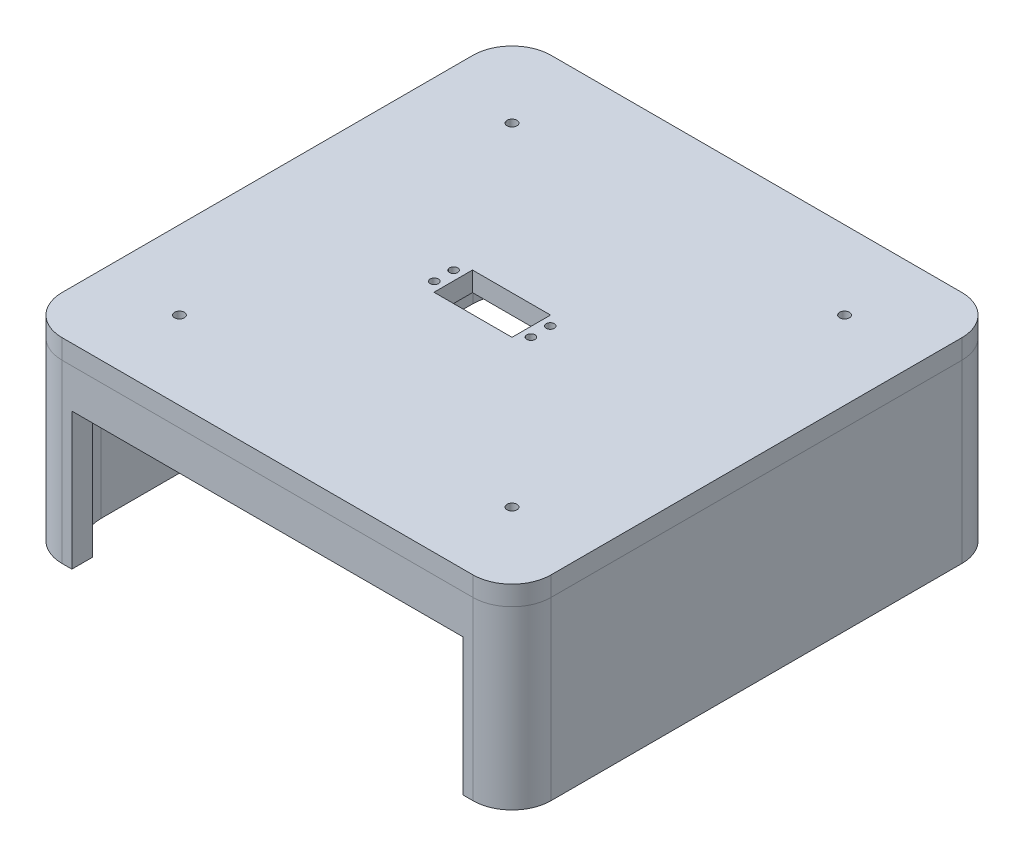
from build123d import *

# Parameters (mm, degrees)
SKETCH1_W            = 250
SKETCH1_H            = 250
SKETCH1_W_2          = 230
SKETCH1_H_2          = 230
BOSS_EXTRUDE1_DEPTH  = 90
SKETCH2_W            = 200
SKETCH2_H            = 70
CUT_EXTRUDE1_DEPTH   = 50
FILLET1_R            = 20
BOSS_EXTRUDE2_DEPTH  = 10
SKETCH4_R            = 2.5
CUT_EXTRUDE2_DEPTH   = 10
LPATTERN1_COUNT      = 2
LPATTERN1_PITCH      = 170
LPATTERN1_COUNT_DIR2 = 2
LPATTERN1_PITCH_DIR2 = 170
SKETCH6_R            = 2.1
SKETCH6_W            = 39.9
SKETCH6_H            = 19.7
CUT_EXTRUDE3_DEPTH   = 10


with BuildPart() as part:
    # Sketch1 → Boss-Extrude1 (new body)
    with BuildSketch(Plane(origin=(0, 0, 0), x_dir=(1, 0, 0), z_dir=(0, 1, 0))):
        Rectangle(SKETCH1_W, SKETCH1_H)
        Rectangle(SKETCH1_W_2, SKETCH1_H_2, mode=Mode.SUBTRACT)
    extrude(amount=BOSS_EXTRUDE1_DEPTH)

    # Sketch2 → Cut-Extrude1 (cut)
    with BuildSketch(Plane.XY.offset(125)):
        with Locations((0, 35)):
            Rectangle(SKETCH2_W, SKETCH2_H)
    extrude(amount=-CUT_EXTRUDE1_DEPTH, mode=Mode.SUBTRACT)

    # Fillet1
    fillet1_edges = [part.edges().sort_by_distance(p)[0] for p in [
        (-115, 45, 115),
        (115, 45, 115),
        (115, 45, -115),
        (-115, 45, -115),
        (-125, 45, 125),
        (125, 45, 125),
        (125, 45, -125),
        (-125, 45, -125),
    ]]
    fillet(fillet1_edges, radius=FILLET1_R)


with BuildPart() as body_2:
    # Sketch3 → Boss-Extrude2 (new body)
    with BuildSketch(Plane(origin=(0, 90, 0), x_dir=(1, 0, 0), z_dir=(0, 1, 0))):
        with BuildLine():
            Line((-105, -125), (105, -125))
            ThreePointArc((105, -125), (119.142135624, -119.142135624), (125, -105))
            Line((125, -105), (125, 105))
            ThreePointArc((125, 105), (119.142135624, 119.142135624), (105, 125))
            Line((105, 125), (-105, 125))
            ThreePointArc((-105, 125), (-119.142135624, 119.142135624), (-125, 105))
            Line((-125, 105), (-125, -105))
            ThreePointArc((-125, -105), (-119.142135624, -119.142135624), (-105, -125))
        make_face()
    extrude(amount=BOSS_EXTRUDE2_DEPTH)

    # Sketch4 → Cut-Extrude2 (cut)
    with BuildSketch(Plane(origin=(0, 100, 0), x_dir=(1, 0, 0), z_dir=(0, 1, 0))):
        with Locations((-85, 85)):
            Circle(SKETCH4_R)
    cut_extrude2 = extrude(amount=-CUT_EXTRUDE2_DEPTH, mode=Mode.SUBTRACT)

    # LPattern1: Cut-Extrude2 2 × 2
    with Locations(*[(i * LPATTERN1_PITCH, 0, j * LPATTERN1_PITCH_DIR2) for i in range(LPATTERN1_COUNT) for j in range(LPATTERN1_COUNT_DIR2) if (i, j) != (0, 0)]):
        add(cut_extrude2, mode=Mode.SUBTRACT)

    # Sketch6 → Cut-Extrude3 (cut)
    with BuildSketch(Plane(origin=(0, 100, 0), x_dir=(1, 0, 0), z_dir=(0, 1, 0))):
        with Locations((-34.811145618, 4.925)):
            Circle(SKETCH6_R)
        with Locations((-34.811145618, -4.925)):
            Circle(SKETCH6_R)
        with Locations((14.611145618, -4.925)):
            Circle(SKETCH6_R)
        with Locations((14.611145618, 4.925)):
            Circle(SKETCH6_R)
        with Locations((-10.1, 0)):
            Rectangle(SKETCH6_W, SKETCH6_H)
    extrude(amount=-CUT_EXTRUDE3_DEPTH, mode=Mode.SUBTRACT)


solid = Compound([part.part, body_2.part])
